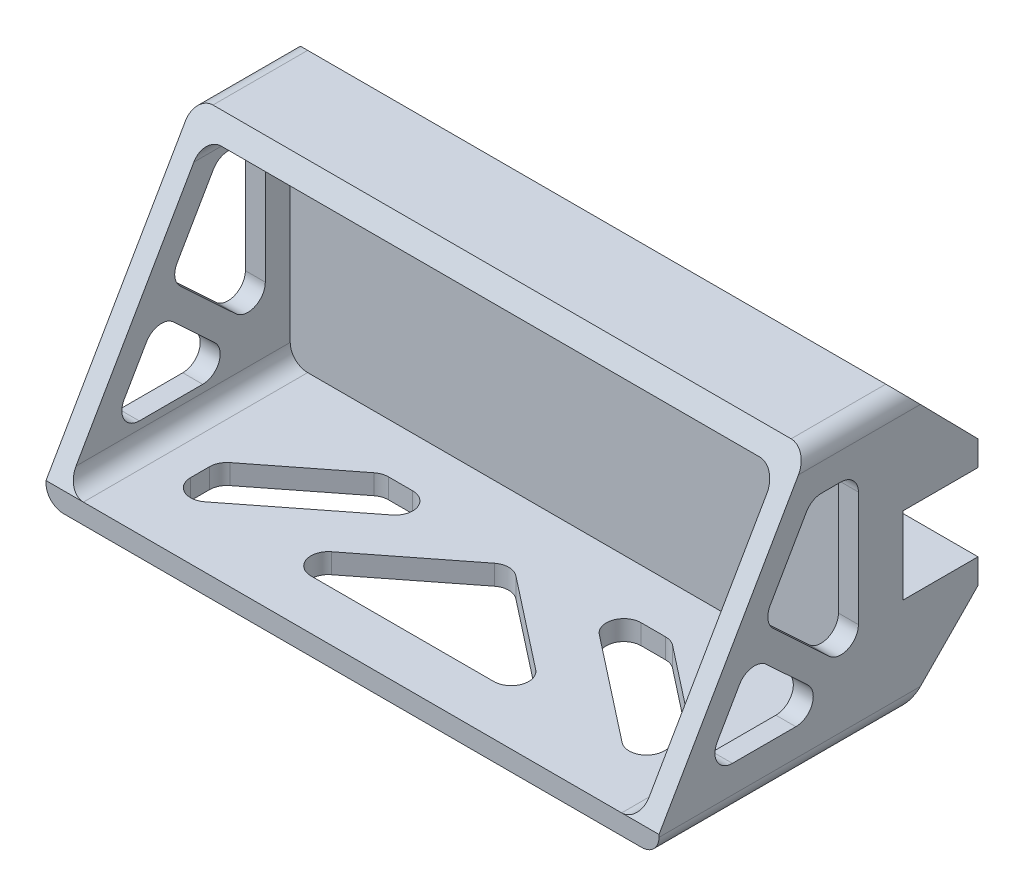
from build123d import *

# Parameters (mm, degrees)
SKETCH1_W           = 123
SKETCH1_H           = 56
BOSS_EXTRUDE1_DEPTH = 4
SKETCH1_3_W         = 123
SKETCH1_3_H         = 56
SKETCH1_3_W_2       = 115
SKETCH1_3_H_2       = 48
BOSS_EXTRUDE2_DEPTH = 49
SKETCH2_W           = 123
SKETCH2_H           = 5
BOSS_EXTRUDE3_DEPTH = 15
BOSS_EXTRUDE4_DEPTH = 5
CUT_EXTRUDE1_DEPTH  = 136.329228181
CUT_EXTRUDE2_DEPTH  = 136.329228181
CUT_EXTRUDE3_DEPTH  = 5
FILLET5_R           = 3.5
FILLET6_R           = 3.5
FILLET7_R           = 3.5
FILLET8_R           = 3.5
SKETCH8_R           = 1.75
CUT_EXTRUDE4_DEPTH  = 89.565300892


with BuildPart() as part:
    # Sketch1 → Boss-Extrude1 (new body)
    with BuildSketch(Plane.XY):
        Rectangle(SKETCH1_W, SKETCH1_H)
    extrude(amount=BOSS_EXTRUDE1_DEPTH)

    # Sketch1_3 → Boss-Extrude2 (add)
    with BuildSketch(Plane.XY):
        Rectangle(SKETCH1_3_W, SKETCH1_3_H)
        Rectangle(SKETCH1_3_W_2, SKETCH1_3_H_2, mode=Mode.SUBTRACT)
    extrude(amount=BOSS_EXTRUDE2_DEPTH)

    # Sketch2 → Boss-Extrude3 (add)
    with BuildSketch(Plane(origin=(0, 0, 0), x_dir=(-1, 0, 0), z_dir=(0, 0, -1))):
        with Locations((0, 10.25)):
            Rectangle(SKETCH2_W, SKETCH2_H)
        with Locations((0, -10.25)):
            Rectangle(SKETCH2_W, SKETCH2_H)
    extrude(amount=BOSS_EXTRUDE3_DEPTH)

    # Sketch3 → Boss-Extrude4 (add)
    with BuildSketch(Plane(origin=(61.5, 0, 0), x_dir=(0, 0, -1), z_dir=(1, 0, 0))):
        Polygon((0, -28), (15, -12.75), (0, -12.75), align=None)
        Polygon((15, 12.75), (0, 28), (0, 12.75), align=None)
    boss_extrude4 = extrude(amount=-BOSS_EXTRUDE4_DEPTH)

    # Mirror1: Boss-Extrude4 across plane
    add(boss_extrude4.mirror(Plane.ZY))

    # Sketch4 → Cut-Extrude1 (cut, through all)
    with BuildSketch(Plane.ZY.offset(61.5)):
        Polygon((19, 28), (49, -24), (49, 24), (49, 28), align=None)
    extrude(amount=-CUT_EXTRUDE1_DEPTH, mode=Mode.SUBTRACT)

    # Sketch6 → Cut-Extrude2 (cut, through all)
    with BuildSketch(Plane.ZY.offset(61.5)):
        Polygon((12.66631443, -19), (40.342949608, -19), (30.66362763, -2.222508572), align=None)
        Polygon((28.088718183, 2.240667802), (18.419872685, 19), (9, 19), (9, -15.582181004), (27.67670193, 1.828651549), align=None)
    extrude(amount=-CUT_EXTRUDE2_DEPTH, mode=Mode.SUBTRACT)

    # Sketch7 → Cut-Extrude3 (cut)
    with BuildSketch(Plane.XZ.offset(28)):
        Polygon((-12.777777778, 14), (-47.5, 41.173913043), (-47.5, 28.475580986), (-29.003424296, 14), align=None)
        Polygon((47.5, 41.173913043), (12.777777778, 14), (29.003424296, 14), (47.5, 28.475580986), align=None)
        Polygon((-28.496575704, 39), (0, 16.698332058), (28.496575704, 39), align=None)
    extrude(amount=-CUT_EXTRUDE3_DEPTH, mode=Mode.SUBTRACT)

    # Fillet5
    fillet5_edges = [part.edges().sort_by_distance(p)[0] for p in [
        (-12.777777778, -26, 14),
        (12.777777778, -26, 14),
        (47.5, -26, 41.173913043),
        (28.496575704, -26, 39),
        (-47.5, -26, 41.173913043),
        (-47.5, -26, 28.475580986),
        (-28.496575704, -26, 39),
        (47.5, -26, 28.475580986),
        (29.003424296, -26, 14),
        (0, -26, 16.698332058),
        (-29.003424296, -26, 14),
    ]]
    fillet(fillet5_edges, radius=FILLET5_R)

    # Fillet6
    fillet6_edges = [part.edges().sort_by_distance(p)[0] for p in [
        (-59.5, 19, 18.419872685),
        (-59.5, 19, 9),
        (-59.5, -15.582181004, 9),
        (-59.5, -19, 12.66631443),
        (-59.5, -19, 40.342949608),
        (-59.5, -2.222508572, 30.66362763),
        (-59.5, 2.240667802, 28.088718183),
        (59.5, -2.222508572, 30.66362763),
        (59.5, 2.240667802, 28.088718183),
        (59.5, -19, 40.342949608),
        (59.5, 19, 9),
        (59.5, 19, 18.419872685),
        (59.5, -19, 12.66631443),
        (59.5, -15.582181004, 9),
    ]]
    fillet(fillet6_edges, radius=FILLET6_R)

    # Fillet7
    fillet7_edges = [part.edges().sort_by_distance(p)[0] for p in [
        (-57.5, 24, 12.653846154),
        (-57.5, -24, 26.5),
        (57.5, 24, 12.653846154),
        (57.5, -24, 26.5),
    ]]
    fillet(fillet7_edges, radius=FILLET7_R)

    # Fillet8
    fillet8_edges = [part.edges().sort_by_distance(p)[0] for p in [
        (-61.5, -28, 24.5),
        (61.5, -28, 24.5),
        (61.5, 28, 9.5),
        (-61.5, 28, 9.5),
    ]]
    fillet(fillet8_edges, radius=FILLET8_R)

    # Sketch8 → Cut-Extrude4 (cut, through all)
    with BuildSketch(Plane(origin=(0, 12.75, 0), x_dir=(1, 0, 0), z_dir=(0, 1, 0))):
        with Locations((40, 7.5)):
            Circle(SKETCH8_R)
        with Locations((-40, 7.5)):
            Circle(SKETCH8_R)
    extrude(amount=-CUT_EXTRUDE4_DEPTH, mode=Mode.SUBTRACT)


solid = part.part
